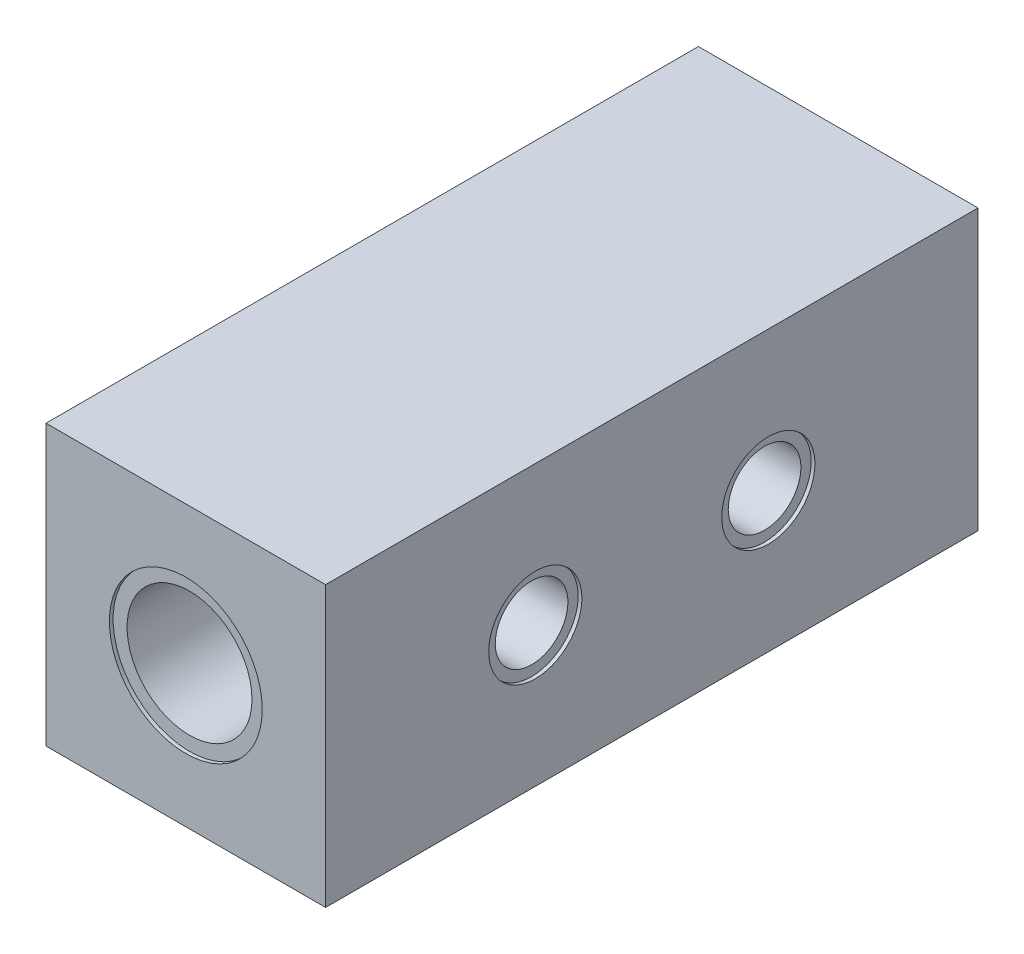
from build123d import *

# Parameters (mm, degrees)
SKETCH1_W           = 38.1
SKETCH1_H           = 38.1
SKETCH1_R           = 8.509
BOSS_EXTRUDE1_DEPTH = 44.45
SKETCH2_R           = 4.953
CUT_EXTRUDE1_DEPTH  = 39.1
CUT_EXTRUDE2_START  = 44.45
SKETCH13_R          = 10.414
CUT_EXTRUDE2_DEPTH  = 0.508
CUT_EXTRUDE3_START  = -44.45
SKETCH13_2_R        = 10.414
CUT_EXTRUDE3_DEPTH  = 0.508
CUT_EXTRUDE4_START  = 19.05
SKETCH14_R          = 6.35
CUT_EXTRUDE4_DEPTH  = 0.508
CUT_EXTRUDE5_START  = 19.05
SKETCH14_3_R        = 6.35
CUT_EXTRUDE5_DEPTH  = 0.508
CUT_EXTRUDE6_START  = -19.05
SKETCH14_4_R        = 6.35
CUT_EXTRUDE6_DEPTH  = 0.508


with BuildPart() as part:
    # Sketch1 → Boss-Extrude1 (new body, symmetric)
    with BuildSketch(Plane.XY):
        Rectangle(SKETCH1_W, SKETCH1_H)
        Circle(SKETCH1_R, mode=Mode.SUBTRACT)
    extrude(amount=BOSS_EXTRUDE1_DEPTH, both=True)

    # Sketch2 → Cut-Extrude1 (cut, through all)
    with BuildSketch(Plane(origin=(19.05, 0, 0), x_dir=(0, 0, -1), z_dir=(1, 0, 0))):
        with Locations((-15.875, 0)):
            Circle(SKETCH2_R)
        with Locations((15.875, 0)):
            Circle(SKETCH2_R)
    extrude(amount=-CUT_EXTRUDE1_DEPTH, mode=Mode.SUBTRACT)

    # Sketch13 → Cut-Extrude2 (cut)
    with BuildSketch(Plane.XY.offset(CUT_EXTRUDE2_START)):
        Circle(SKETCH13_R)
    extrude(amount=-CUT_EXTRUDE2_DEPTH, mode=Mode.SUBTRACT)

    # Sketch13_2 → Cut-Extrude3 (cut)
    with BuildSketch(Plane.XY.offset(CUT_EXTRUDE3_START)):
        Circle(SKETCH13_2_R)
    extrude(amount=CUT_EXTRUDE3_DEPTH, mode=Mode.SUBTRACT)

    # Sketch14 → Cut-Extrude4 (cut)
    with BuildSketch(Plane(origin=(0, 0, 0), x_dir=(0, 0, -1), z_dir=(1, 0, 0)).offset(CUT_EXTRUDE4_START)):
        with Locations((-15.875, 0)):
            Circle(SKETCH14_R)
    extrude(amount=-CUT_EXTRUDE4_DEPTH, mode=Mode.SUBTRACT)

    # Sketch14_3 → Cut-Extrude5 (cut)
    with BuildSketch(Plane(origin=(0, 0, 0), x_dir=(0, 0, -1), z_dir=(1, 0, 0)).offset(CUT_EXTRUDE5_START)):
        with Locations((-15.875, 0)):
            Circle(SKETCH14_3_R)
        with Locations((15.875, 0)):
            Circle(SKETCH14_3_R)
    extrude(amount=-CUT_EXTRUDE5_DEPTH, mode=Mode.SUBTRACT)

    # Sketch14_4 → Cut-Extrude6 (cut)
    with BuildSketch(Plane(origin=(0, 0, 0), x_dir=(0, 0, -1), z_dir=(1, 0, 0)).offset(CUT_EXTRUDE6_START)):
        with Locations((-15.875, 0)):
            Circle(SKETCH14_4_R)
        with Locations((15.875, 0)):
            Circle(SKETCH14_4_R)
    extrude(amount=CUT_EXTRUDE6_DEPTH, mode=Mode.SUBTRACT)


solid = part.part
